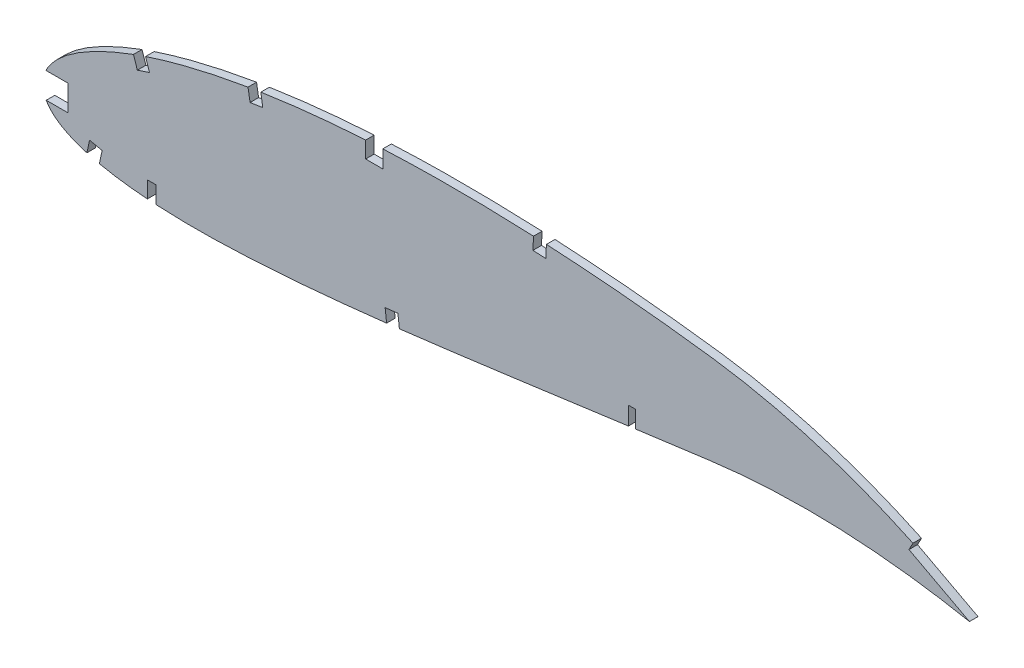
from build123d import *

# Parameters (mm, degrees)
BOSS_EXTRUDE1_DEPTH = 3.175
SKETCH2_W           = 3.175
SKETCH2_H           = 6.35
CUT_EXTRUDE1_DEPTH  = 7.62
SKETCH3_W           = 9.525
SKETCH3_H           = 9.525
CUT_EXTRUDE2_DEPTH  = 7.62
CUT_EXTRUDE3_DEPTH  = 356.490626345


with BuildPart() as part:
    # Sketch1 → Boss-Extrude1 (new body)
    with BuildSketch(Plane.XY):
        with BuildLine():
            Line((349.874585492, 0.545463984), (352.707444634, -1.20455312))
            Line((352.707444634, -1.20455312), (349.438214508, -0.545463984))
            add(Edge.make_bspline(
                [(0, 0), (0.089846556, -0.42413566), (0.269952586, -1.274356233), (0.759277158, -2.498321594), (1.406385548, -3.674906843), (2.224859075, -4.800986693), (3.209255672, -5.876253384), (4.35740119, -6.901825315), (5.668169647, -7.877151063), (7.139845481, -8.801786749), (8.770290863, -9.676713909), (10.557673174, -10.501388578), (12.50036268, -11.27555304), (14.596242771, -11.998172434), (16.842751177, -12.670347293), (19.237752029, -13.290439574), (21.778521975, -13.85931597), (24.462617274, -14.375524359), (27.287113095, -14.839589189), (30.249075184, -15.251250745), (33.345463294, -15.610766498), (36.573239638, -15.91738207), (39.929211619, -16.171756957), (43.410034297, -16.374059922), (47.012328898, -16.524932447), (50.732644804, -16.623800998), (54.567338391, -16.67220693), (58.512944169, -16.670876946), (62.565602395, -16.61945532), (66.721851142, -16.520782763), (70.977702027, -16.374234263), (75.329312874, -16.181583233), (79.772758472, -15.944768433), (84.304053533, -15.664592692), (88.919210366, -15.34229772), (93.614221743, -14.980468162), (98.384822681, -14.580006537), (103.226852581, -14.143247039), (108.136024765, -13.672376169), (113.108097791, -13.168884156), (118.138682919, -12.635139453), (123.223299496, -12.072871655), (128.357622076, -11.485080459), (133.536960473, -10.872829323), (138.756934998, -10.239613946), (144.01263497, -9.586644137), (149.299665563, -8.916434941), (154.613271597, -8.232142042), (159.948478634, -7.533687389), (165.300799385, -6.826047184), (170.665072246, -6.10863863), (176.036627988, -5.385151352), (181.41049421, -4.657834169), (186.781436724, -3.926910937), (192.144734283, -3.195410776), (197.495411502, -2.465341803), (202.828227289, -1.736770722), (208.138356857, -1.01331884), (213.420453064, -0.29489769), (218.669645291, 0.417036129), (223.880903334, 1.120357576), (229.04931062, 1.814178993), (234.169535605, 2.498061398), (239.236426935, 3.172261632), (244.169031168, 3.816316009), (248.954459394, 4.464520656), (253.608837564, 4.995904796), (258.205262858, 5.449460294), (262.748509733, 5.821313195), (267.233122793, 6.116813381), (271.653963676, 6.33807231), (276.005763649, 6.488179014), (280.283025782, 6.571586638), (284.480407554, 6.590411838), (288.592179833, 6.550658117), (292.612994804, 6.455529945), (296.537240729, 6.309297175), (300.359442953, 6.116893422), (304.074172418, 5.88356379), (307.675852222, 5.61275005), (311.159463489, 5.31077448), (314.519631517, 4.982057677), (317.751196762, 4.630355277), (320.849443917, 4.263036843), (323.80941387, 3.882520808), (326.626654369, 3.495060385), (329.296630419, 3.104582143), (331.815113594, 2.716071228), (334.178146904, 2.333234142), (336.381913315, 1.961151961), (338.42296059, 1.603301248), (340.297747089, 1.263176546), (342.003671937, 0.945069457), (343.537365938, 0.650560023), (344.89677779, 0.384501923), (346.079379905, 0.148069019), (347.083438644, -0.055407417), (347.907200564, -0.225124582), (348.549414458, -0.358296262), (349.008811888, -0.455135342), (349.284895944, -0.512759554), (349.407563654, -0.538925841), (349.438214508, -0.545463984)],
                knots=[0, 0, 0, 0, 0.003638255, 0.007293231, 0.011028136, 0.014901081, 0.018963272, 0.023258475, 0.027820626, 0.032679082, 0.03785316, 0.043361875, 0.049214679, 0.055422346, 0.061988786, 0.068918036, 0.076211157, 0.083868392, 0.091887411, 0.100265912, 0.108999867, 0.118084529, 0.127514843, 0.13728527, 0.147387917, 0.15781648, 0.168563473, 0.179619128, 0.190977373, 0.202626974, 0.214560478, 0.226767249, 0.239236417, 0.251959004, 0.264923894, 0.278119702, 0.291536035, 0.305160279, 0.318980685, 0.332985499, 0.34716279, 0.361498602, 0.375980747, 0.390597192, 0.405332593, 0.420174823, 0.435109532, 0.450124275, 0.465203067, 0.480333154, 0.495500583, 0.510689775, 0.525887334, 0.541078314, 0.556247233, 0.571381784, 0.58646604, 0.601484516, 0.616424328, 0.631269422, 0.646006524, 0.660620684, 0.675098187, 0.689422858, 0.703581824, 0.716907563, 0.730009274, 0.742952128, 0.755725558, 0.768319951, 0.780724337, 0.792926529, 0.804916041, 0.816679084, 0.828203524, 0.8394749, 0.850481359, 0.861207696, 0.871639325, 0.881763414, 0.891563605, 0.901027364, 0.910138977, 0.918883976, 0.927249278, 0.935221103, 0.942784738, 0.949928187, 0.956638464, 0.962904203, 0.968712287, 0.974054484, 0.978918432, 0.983297218, 0.987180246, 0.990560674, 0.993433357, 0.995790625, 0.997629587, 0.998945816, 0.999736592, 1, 1, 1, 1], degree=3))
            add(Edge.make_bspline(
                [(349.874585492, 0.545463984), (349.84778287, 0.562021478), (349.740676385, 0.628187203), (349.499345966, 0.776216), (349.097480631, 1.022765407), (348.534904305, 1.366122907), (347.812053852, 1.805376859), (346.928565422, 2.337451142), (345.884990684, 2.960617427), (344.681582261, 3.67192829), (343.318463463, 4.468053151), (341.796153348, 5.345766934), (340.114784198, 6.300100143), (338.275007553, 7.327153668), (336.277454595, 8.422042859), (334.122503071, 9.57982248), (331.810924623, 10.794603269), (329.343606792, 12.061160753), (326.720999264, 13.372500177), (323.94433864, 14.723164515), (321.014549884, 16.106419105), (317.932632954, 17.514883916), (314.700358537, 18.942817663), (311.318620248, 20.381342636), (307.789345254, 21.824226627), (304.114035971, 23.263257402), (300.294868588, 24.691881816), (296.333316521, 26.10084431), (292.232341223, 27.48398811), (287.993932043, 28.832327649), (283.621119941, 30.138540114), (279.116445698, 31.394156819), (274.483664423, 32.592738274), (269.725714187, 33.725555633), (264.846627655, 34.785026629), (259.850283242, 35.764772317), (254.74087123, 36.65501141), (249.532550289, 37.455049817), (244.309121072, 38.12054629), (239.096438625, 38.773245817), (233.891519128, 39.386397341), (228.62298462, 39.973574713), (223.295903739, 40.531472038), (217.915560522, 41.058344765), (212.48740178, 41.551918975), (207.017068371, 42.010747226), (201.50985363, 42.432229596), (195.971564619, 42.815716764), (190.407676675, 43.157837372), (184.824116001, 43.458334576), (179.226550658, 43.715112597), (173.620805826, 43.926402175), (168.012834012, 44.090927801), (162.408456479, 44.20711327), (156.813741345, 44.274228097), (151.234507983, 44.290438421), (145.676821678, 44.255454251), (140.146502239, 44.168074381), (134.649621139, 44.027102616), (129.192006124, 43.832275845), (123.779558755, 43.583678577), (118.418205112, 43.279228984), (113.113761309, 42.92086723), (107.872134275, 42.507087935), (102.699083074, 42.03778105), (97.60002911, 41.514902823), (92.580649376, 40.937031104), (87.646323129, 40.305810102), (82.802447525, 39.62247743), (78.054457529, 38.886660836), (73.407439292, 38.100485727), (68.866408275, 37.264756455), (64.436168878, 36.381923118), (60.121544455, 35.452216047), (55.927102264, 34.478424084), (51.857201424, 33.462243838), (47.916216984, 32.405535604), (44.108143965, 31.310835019), (40.436833156, 30.180625631), (36.906564432, 29.016149332), (33.520005897, 27.821821268), (30.281317597, 26.598489281), (27.192980463, 25.349922105), (24.25861379, 24.07782455), (21.480409666, 22.78607462), (18.861512382, 21.476142937), (16.403788439, 20.151699481), (14.109705191, 18.814775138), (11.981470954, 17.46785311), (10.019980202, 16.114349944), (8.227937298, 14.75511519), (6.605957835, 13.393583581), (5.155068251, 12.031828375), (3.87734245, 10.670787626), (2.772734444, 9.312858131), (1.842691864, 7.959115327), (1.087376063, 6.610840176), (0.508495443, 5.269012088), (0.105475974, 3.934385674), (-0.11513418, 2.608930803), (-0.170045383, 1.291584884), (-0.056597102, 0.42988501), (0, 0)],
                knots=[0, 0, 0, 0, 0.00025409, 0.001015373, 0.002283359, 0.004056577, 0.006330981, 0.009105274, 0.012374489, 0.016134023, 0.02037966, 0.025105976, 0.030306237, 0.035972206, 0.042099522, 0.048678063, 0.055701664, 0.063160184, 0.071045824, 0.079349826, 0.08806291, 0.097175756, 0.106678112, 0.116561573, 0.126814275, 0.1374283, 0.148393617, 0.15969976, 0.171338125, 0.183297699, 0.195569604, 0.208143556, 0.221011593, 0.234161831, 0.24758745, 0.261276823, 0.27522271, 0.289414144, 0.3037712, 0.317689226, 0.331784111, 0.346039676, 0.360443869, 0.37498272, 0.389640454, 0.404403316, 0.419256601, 0.434186749, 0.449177265, 0.464214782, 0.479284009, 0.49436974, 0.509457833, 0.524532346, 0.53957932, 0.554582984, 0.569529546, 0.584403417, 0.599190992, 0.613876838, 0.628447475, 0.642888675, 0.657186054, 0.671325546, 0.685294014, 0.699078147, 0.712665095, 0.726042645, 0.739197713, 0.752117586, 0.764792042, 0.777208152, 0.789355685, 0.80122396, 0.812803685, 0.824082909, 0.835054602, 0.845709571, 0.856037853, 0.866033834, 0.875688843, 0.884997719, 0.893953426, 0.902552897, 0.910789386, 0.918660734, 0.926166253, 0.933302626, 0.94007122, 0.94647478, 0.952517526, 0.958204819, 0.963546652, 0.9685566, 0.973249913, 0.977651041, 0.981787043, 0.985694226, 0.989415109, 0.993001157, 0.996508416, 1, 1, 1, 1], degree=3))
        make_face()
    extrude(amount=BOSS_EXTRUDE1_DEPTH)

    # Sketch2 → Cut-Extrude1 (cut)
    with BuildSketch(Plane(origin=(0, 0, 0), x_dir=(-1, 0, 0), z_dir=(0, 0, -1))):
        Polygon((-219.606554447, 6.914833959), (-217.066554447, 6.914833959), (-217.066554447, 0.564687977), (-217.066554447, -0.789930881), (-219.606554447, -0.112621452), (-219.606554447, 0.564687977), align=None)
        Polygon((-125.944054447, 43.593406611), (-125.944054447, 37.241023539), (-119.594054447, 37.241023539), (-119.594054447, 43.593406611), (-119.594054447, 44.802397228), (-125.944054447, 46.495670801), align=None)
        with Locations((-40.219054447, -13.103372293)):
            Rectangle(SKETCH2_W, SKETCH2_H)
    extrude(amount=-CUT_EXTRUDE1_DEPTH, mode=Mode.SUBTRACT)

    # Sketch3 → Cut-Extrude2 (cut)
    with BuildSketch(Plane.XY.offset(3.175)):
        with Locations((4.355371843, 1.645821512)):
            Rectangle(SKETCH3_W, SKETCH3_H)
        Polygon((16.171457382, -12.545249924), (15.705940357, -14.401888263), (20.327485108, -15.560653391), (20.793002133, -13.704015053), (21.83918578, -8.906732132), (17.186142344, -7.892061471), align=None)
        with BuildLine():
            Line((39.42133882, 24.947712418), (37.914907365, 29.465538685))
            add(Edge.make_bspline(
                [(37.914907365, 29.465538685), (37.503075491, 29.328229708), (35.998678939, 28.820692893), (34.501078585, 28.29321423), (33.417210722, 27.898290266)],
                knots=[0, 0, 0, 0, 0.273427544, 1, 1, 1, 1], degree=3))
            Line((33.417210722, 27.898290266), (34.903383719, 23.441235893))
            Line((34.903383719, 23.441235893), (39.42133882, 24.947712418))
        make_face()
        Polygon((127.368342473, -11.617537485), (127.634396869, -13.885543313), (132.379617898, -13.328892664), (132.113563501, -11.060886836), (131.550455412, -6.324317398), (126.821258672, -6.886548949), align=None)
        with BuildLine():
            Line((81.423558796, 34.68031468), (80.699379538, 39.387502266))
            add(Edge.make_bspline(
                [(80.699379538, 39.387502266), (79.775759227, 39.245393844), (78.185850824, 38.994290384), (76.597742692, 38.732069255), (75.931982079, 38.620080212)],
                knots=[0, 0, 0, 0, 0.580571145, 1, 1, 1, 1], degree=3))
            Line((75.931982079, 38.620080212), (76.716438453, 33.956145329))
            Line((76.716438453, 33.956145329), (81.423558796, 34.68031468))
        make_face()
        with BuildLine():
            Line((186.403364239, 38.691487846), (186.65218162, 43.447445327))
            ThreePointArc((186.65218162, 43.447445327), (184.257847491, 43.568655733), (181.863115977, 43.681743585))
            Line((181.863115977, 43.681743585), (181.647368287, 38.940234557))
            Line((181.647368287, 38.940234557), (186.403364239, 38.691487846))
        make_face()
    extrude(amount=-CUT_EXTRUDE2_DEPTH, mode=Mode.SUBTRACT)

    # Sketch4 → Cut-Extrude3 (cut, through all)
    with BuildSketch(Plane.XY.offset(3.175)):
        Polygon((345.059559803, 3.447972415), (343.572178579, 0.642919458), (321.131754919, 12.54196925), (322.619136143, 15.347022208), align=None)
        with BuildLine():
            add(Edge.make_bspline(
                [(349.874585492, 0.545463984), (349.84778287, 0.562021478), (349.740676385, 0.628187203), (349.499345966, 0.776216), (349.097480631, 1.022765407), (348.534904305, 1.366122907), (347.812053852, 1.805376859), (346.928565422, 2.337451142), (345.993477074, 2.895835233), (345.352264045, 3.275406174), (345.059559803, 3.447972415)],
                knots=[0, 0, 0, 0, 0.00025409, 0.001015373, 0.002283359, 0.004056577, 0.006330981, 0.009105274, 0.012374489, 0.015114933, 0.015114933, 0.015114933, 0.015114933], degree=3))
            Line((345.059559803, 3.447972415), (343.572178579, 0.642919458))
            add(Edge.make_bspline(
                [(343.572178579, 0.642919458), (343.579821196, 0.641437383), (344.041016928, 0.55198767), (344.89677779, 0.384501923), (346.079379905, 0.148069019), (347.083438644, -0.055407417), (347.907200564, -0.225124582), (348.549414458, -0.358296262), (349.008811888, -0.455135342), (349.284895944, -0.512759554), (349.407563654, -0.538925841), (349.438214508, -0.545463984)],
                knots=[0.983231787, 0.983231787, 0.983231787, 0.983231787, 0.983297218, 0.987180246, 0.990560674, 0.993433357, 0.995790625, 0.997629587, 0.998945816, 0.999736592, 1, 1, 1, 1], degree=3))
            Line((349.438214508, -0.545463984), (349.948597276, -0.648359077))
            add(Edge.make_bspline(
                [(349.948597276, -0.648359077), (350.500766911, -0.746842022), (351.06555297, -0.785669374), (351.683710492, -0.572134715)],
                knots=[1.001458582, 1.001458582, 1.001458582, 1.001458582, 1.006170265, 1.006170265, 1.006170265, 1.006170265], degree=3))
            Line((351.683710492, -0.572134715), (349.874585492, 0.545463984))
        make_face()
        with BuildLine():
            Line((342.714805182, 4.691280136), (328.461146103, 12.249292483))
            add(Edge.make_bspline(
                [(324.765445508, 12.018763987), (325.996981483, 12.098316147), (327.228877956, 12.175186708), (328.461146103, 12.249292483)],
                knots=[0.930148817, 0.930148817, 0.930148817, 0.930148817, 0.940496303, 0.940496303, 0.940496303, 0.940496303], degree=3))
            add(Edge.make_bspline(
                [(342.714805182, 4.691280136), (336.780215271, 7.258818872), (330.795468333, 9.701313741), (324.765445508, 12.018763987)],
                knots=[0.025548456, 0.025548456, 0.025548456, 0.025548456, 0.077569245, 0.077569245, 0.077569245, 0.077569245], degree=3))
        make_face()
    extrude(amount=-CUT_EXTRUDE3_DEPTH, mode=Mode.SUBTRACT)


with BuildPart() as cut_extrude3_kept_piece:
    # of the separate pieces the step leaves, the one the design keeps (cut_extrude3_pieces_kept)
    add(part.part.solids().sort_by_distance((186.647485971, 43.357691522, 0))[0])


solid = cut_extrude3_kept_piece.part
